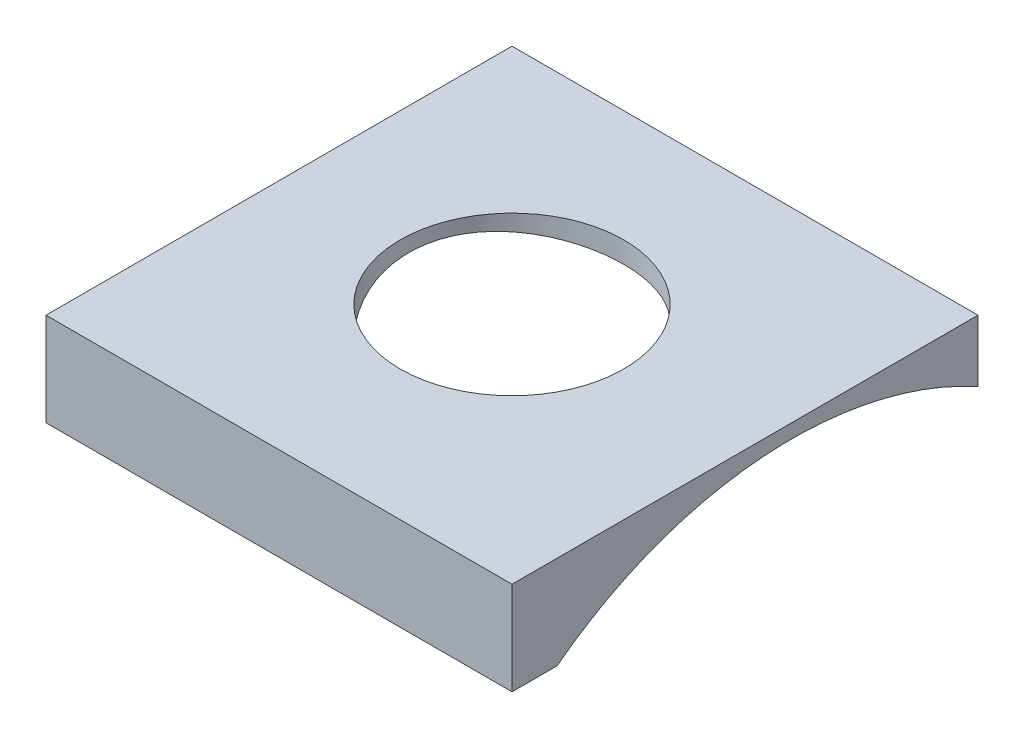
from build123d import *

# Parameters (mm, degrees)
SKETCH1_W          = 25
SKETCH1_H          = 25
SKETCH1_R          = 6
EXTRUDE1_DEPTH     = 5
SKETCH2_R          = 20.75
CUT_EXTRUDE1_DEPTH = 26


with BuildPart() as part:
    # Sketch1 → Extrude1 (new body)
    with BuildSketch(Plane(origin=(0, 0, 0), x_dir=(1, 0, 0), z_dir=(0, 1, 0))):
        with Locations((12.5, -12.5)):
            Rectangle(SKETCH1_W, SKETCH1_H)
        with Locations(Location((12, -12, 0), (0, 0, 270))):  # turned: the seam where the file's is
            Circle(SKETCH1_R, mode=Mode.SUBTRACT)
    extrude(amount=-EXTRUDE1_DEPTH)

    # Sketch2 → Cut-Extrude1 (cut, through all)
    with BuildSketch(Plane(origin=(0, 0, 0), x_dir=(0, 0, -1), z_dir=(1, 0, 0))):
        with Locations((-10, -21.5)):
            Circle(SKETCH2_R)
    extrude(amount=CUT_EXTRUDE1_DEPTH, mode=Mode.SUBTRACT)


solid = part.part
